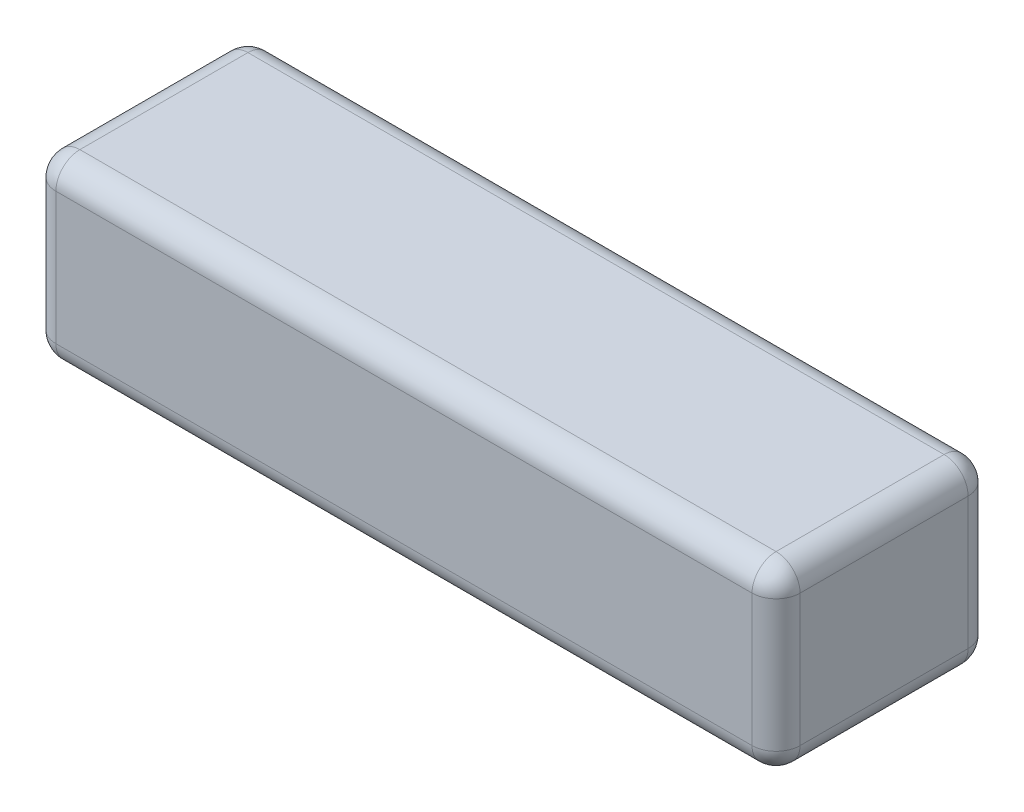
from build123d import *

# Parameters (mm, degrees)
SKETCH1_W           = 62
SKETCH1_H           = 18
BOSS_EXTRUDE1_DEPTH = 7.5
FILLET1_R           = 2


with BuildPart() as part:
    # Sketch1 → Boss-Extrude1 (new body, symmetric)
    with BuildSketch(Plane(origin=(0, 0, 0), x_dir=(1, 0, 0), z_dir=(0, 1, 0))):
        Rectangle(SKETCH1_W, SKETCH1_H)
    extrude(amount=BOSS_EXTRUDE1_DEPTH, both=True)

    # Fillet1
    fillet1_edges = [part.edges().sort_by_distance(p)[0] for p in [
        (-31, 7.5, 0),
        (0, 7.5, 9),
        (31, 7.5, 0),
        (0, -7.5, 9),
        (-31, -7.5, 0),
        (0, -7.5, -9),
        (31, -7.5, 0),
        (31, 0, 9),
        (-31, 0, 9),
        (-31, 0, -9),
        (31, 0, -9),
        (0, 7.5, -9),
    ]]
    fillet(fillet1_edges, radius=FILLET1_R)


solid = part.part
